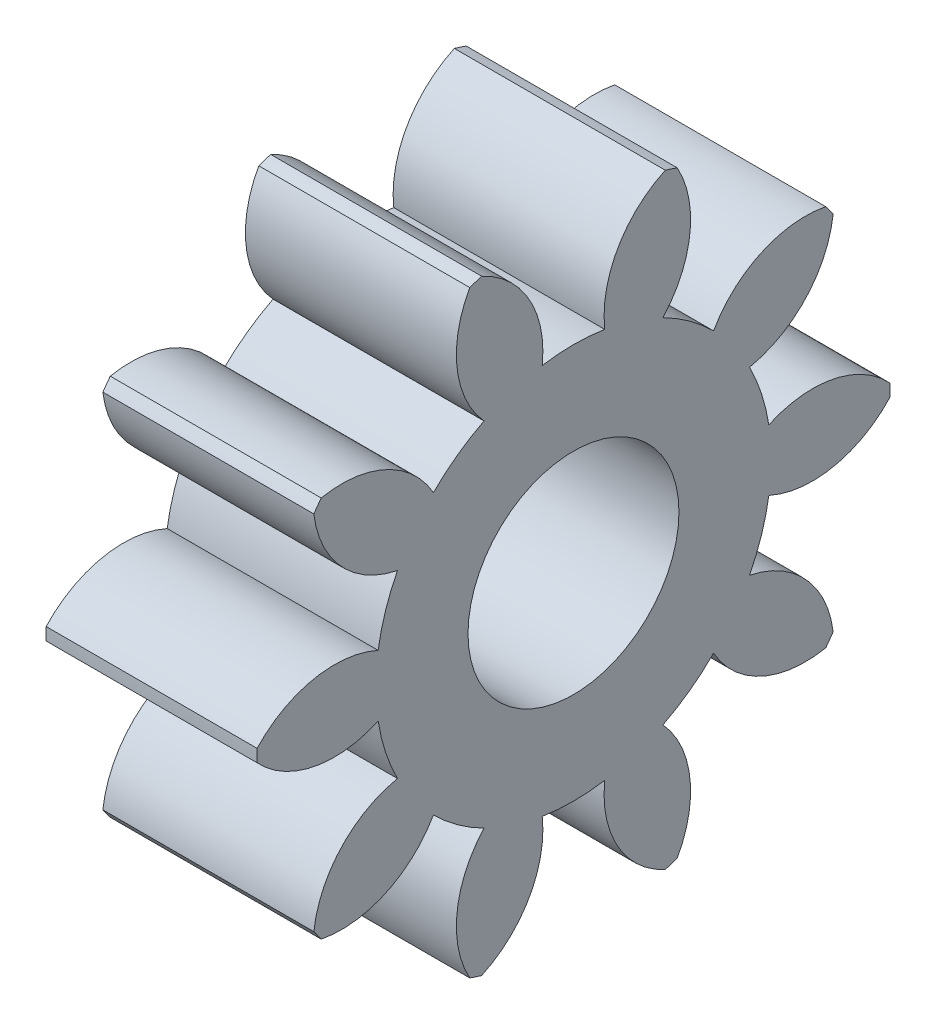
from build123d import *

# Parameters (mm, degrees)
BASPROSKE_W     = 4
BASPROSKE_H     = 6
TOOTHCUT_DEPTH  = 10.38083152
TEETHCUTS_COUNT = 10
TEETHCUTS_ANGLE = 324
BORSKE_R        = 2
BORE_DEPTH      = 50.0000508


with BuildPart() as part:
    # BasProSke → Base-Revolve (revolve)
    with BuildSketch(Plane(origin=(0, 0, 0), x_dir=(1, 0, 0), z_dir=(0, 1, 0)), mode=Mode.PRIVATE) as base_revolve_sk:
        with Locations((2, 3)):
            Rectangle(BASPROSKE_W, BASPROSKE_H)
    revolve(base_revolve_sk.sketch.rotate(Axis((-10, 0, 0), (1, 0, 0)), 180), axis=Axis((-10, 0, 0), (1, 0, 0)))

    # TooCutSke → ToothCut (cut, through all)
    with BuildSketch(Plane(origin=(0, 0, 0), x_dir=(0, 0, -1), z_dir=(1, 0, 0))):
        with BuildLine():
            ThreePointArc((0.59278292, 3.701838653), (0, 3.749), (-0.59278292, 3.701838653))
            ThreePointArc((-0.59278292, 3.701838653), (-0.846593509, 4.924114224), (-1.775771316, 5.757784417))
            ThreePointArc((-1.775771316, 5.757784417), (0, 6.0254), (1.775771316, 5.757784417))
            ThreePointArc((1.775771316, 5.757784417), (0.846593509, 4.924114224), (0.59278292, 3.701838653))
        make_face()
    toothcut = extrude(amount=TOOTHCUT_DEPTH, mode=Mode.SUBTRACT)

    # TeethCuts: ToothCut ×10 about axis
    teethcuts_axis = Axis((-10, 0, 0), (1, 0, 0))
    for i in range(1, TEETHCUTS_COUNT):
        add(toothcut.rotate(teethcuts_axis, i * TEETHCUTS_ANGLE / (TEETHCUTS_COUNT - 1)), mode=Mode.SUBTRACT)

    # BorSke → Bore (cut, symmetric)
    with BuildSketch(Plane(origin=(0, 0, 0), x_dir=(0, 0, -1), z_dir=(1, 0, 0))):
        with Locations(Location((0, 0, 0), (0, 0, 180))):
            Circle(BORSKE_R)
    extrude(amount=BORE_DEPTH, both=True, mode=Mode.SUBTRACT)


solid = part.part
